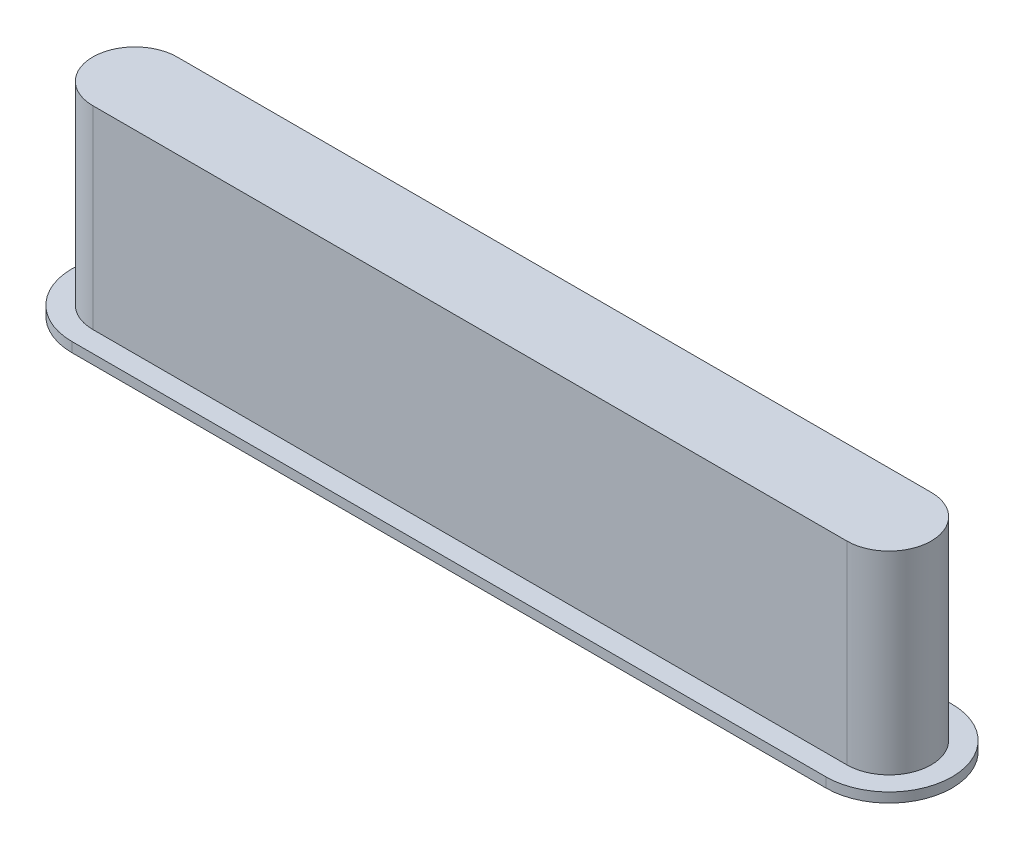
from build123d import *

# Parameters (mm, degrees)
BOSS_EXTRUDE1_DEPTH = 5.08
BOSS_EXTRUDE2_DEPTH = 0.254


with BuildPart() as part:
    # Sketch1 → Boss-Extrude1 (new body)
    with BuildSketch(Plane(origin=(0, 0, 0), x_dir=(1, 0, 0), z_dir=(0, 1, 0))):
        with BuildLine():
            Line((-9.8806, 1.1049), (9.8806, 1.1049))
            ThreePointArc((9.8806, 1.1049), (10.9855, 0), (9.8806, -1.1049))
            Line((9.8806, -1.1049), (-9.8806, -1.1049))
            ThreePointArc((-9.8806, -1.1049), (-10.9855, 0), (-9.8806, 1.1049))
        make_face()
    extrude(amount=BOSS_EXTRUDE1_DEPTH)

    # Sketch3 → Boss-Extrude2 (add)
    with BuildSketch(Plane(origin=(0, 0, 0), x_dir=(1, 0, 0), z_dir=(0, 1, 0))):
        with BuildLine():
            Line((-9.8806, 1.651), (9.8806, 1.651))
            ThreePointArc((9.8806, 1.651), (11.5316, 0), (9.8806, -1.651))
            Line((9.8806, -1.651), (-9.8806, -1.651))
            ThreePointArc((-9.8806, -1.651), (-11.5316, 0), (-9.8806, 1.651))
        make_face()
    extrude(amount=-BOSS_EXTRUDE2_DEPTH)


solid = part.part
